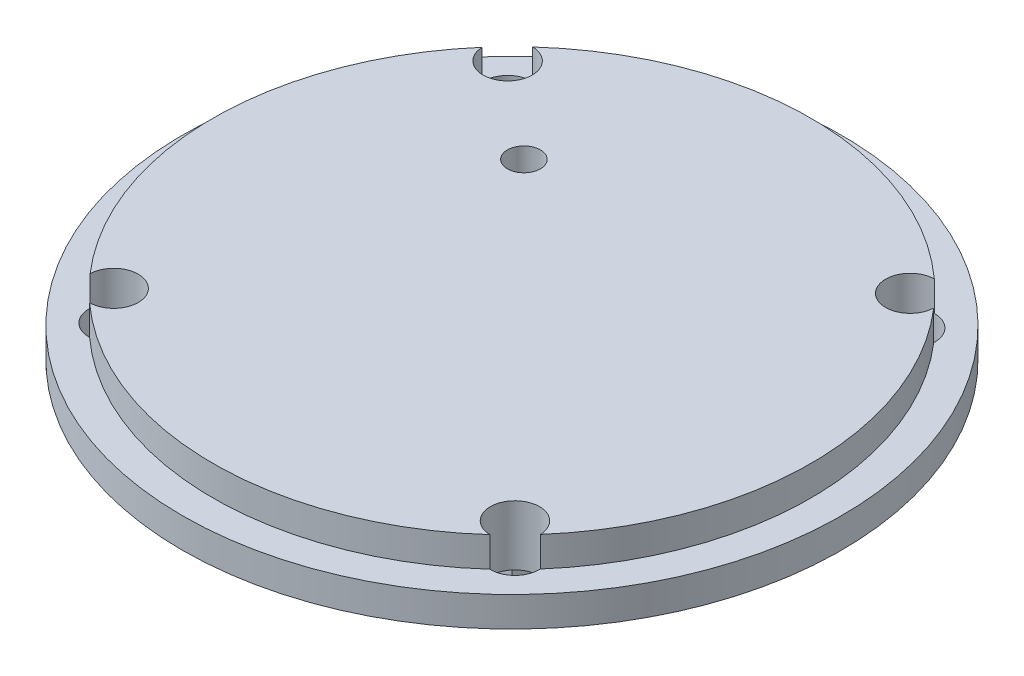
from build123d import *

# Parameters (mm, degrees)
SKETCH_1_R          = 55
EXTRUDE_1_DEPTH     = 5
SKETCH_2_R          = 49.9
EXTRUDE_2_DEPTH     = 5
SKETCH_3_W          = 30
SKETCH_3_H          = 30
EXTRUDE_3_DEPTH     = 20
SKETCH_4_W          = 20.2
SKETCH_4_H          = 10.2
CUT_EXTRUDE_1_DEPTH = 71
SKETCH_5_R          = 4.1
CUT_EXTRUDE_2_DEPTH = 11
SKETCH_6_R          = 2.75
CUT_EXTRUDE_3_DEPTH = 31


with BuildPart() as part:
    # Эскиз1 → Бобышка-Вытянуть1 (new body)
    with BuildSketch(Plane(origin=(0, 0, 0), x_dir=(1, 0, 0), z_dir=(0, 1, 0))):
        with Locations(Location((0, 0, 0), (0, 0, 270))):  # turned: the seam where the file's is
            Circle(SKETCH_1_R)
    extrude(amount=EXTRUDE_1_DEPTH)

    # Эскиз2 → Бобышка-Вытянуть2 (add)
    with BuildSketch(Plane(origin=(0, 5, 0), x_dir=(1, 0, 0), z_dir=(0, 1, 0))):
        with Locations(Location((0, 0, 0), (0, 0, 270))):  # turned: the seam where the file's is
            Circle(SKETCH_2_R)
    extrude(amount=EXTRUDE_2_DEPTH)

    # Эскиз3 → Бобышка-Вытянуть3 (add)
    with BuildSketch(Plane.XZ):
        Rectangle(SKETCH_3_W, SKETCH_3_H)
    extrude(amount=EXTRUDE_3_DEPTH)

    # Эскиз4 → Вырез-Вытянуть1 (cut, through all)
    with BuildSketch(Plane.XY.offset(15)):
        with Locations((0, -10)):
            Rectangle(SKETCH_4_W, SKETCH_4_H)
    extrude(amount=-CUT_EXTRUDE_1_DEPTH, mode=Mode.SUBTRACT)

    # Эскиз5 → Вырез-Вытянуть2 (cut, through all)
    with BuildSketch(Plane.XZ):
        with Locations(Location((33.592198598, -32.871936263, 0), (0, 0, 270))):  # turned: the seam where the file's is
            Circle(SKETCH_5_R)
        with Locations(Location((-33.591727056, -32.872418125, 0), (0, 0, 270))):  # turned: the seam where the file's is
            Circle(SKETCH_5_R)
        with Locations(Location((-33.591727056, 32.872418125, 0), (0, 0, 270))):  # turned: the seam where the file's is
            Circle(SKETCH_5_R)
        with Locations(Location((33.483215177, 32.983215177, 0), (0, 0, 270))):  # turned: the seam where the file's is
            Circle(SKETCH_5_R)
    extrude(amount=-CUT_EXTRUDE_2_DEPTH, mode=Mode.SUBTRACT)

    # Эскиз6 → Вырез-Вытянуть3 (cut, through all)
    with BuildSketch(Plane(origin=(0, 10, 0), x_dir=(1, 0, 0), z_dir=(0, 1, 0))):
        with Locations(Location((-17.999856554, 19.999999999, 0), (0, 0, 270))):  # turned: the seam where the file's is
            Circle(SKETCH_6_R)
    extrude(amount=-CUT_EXTRUDE_3_DEPTH, mode=Mode.SUBTRACT)


solid = part.part
